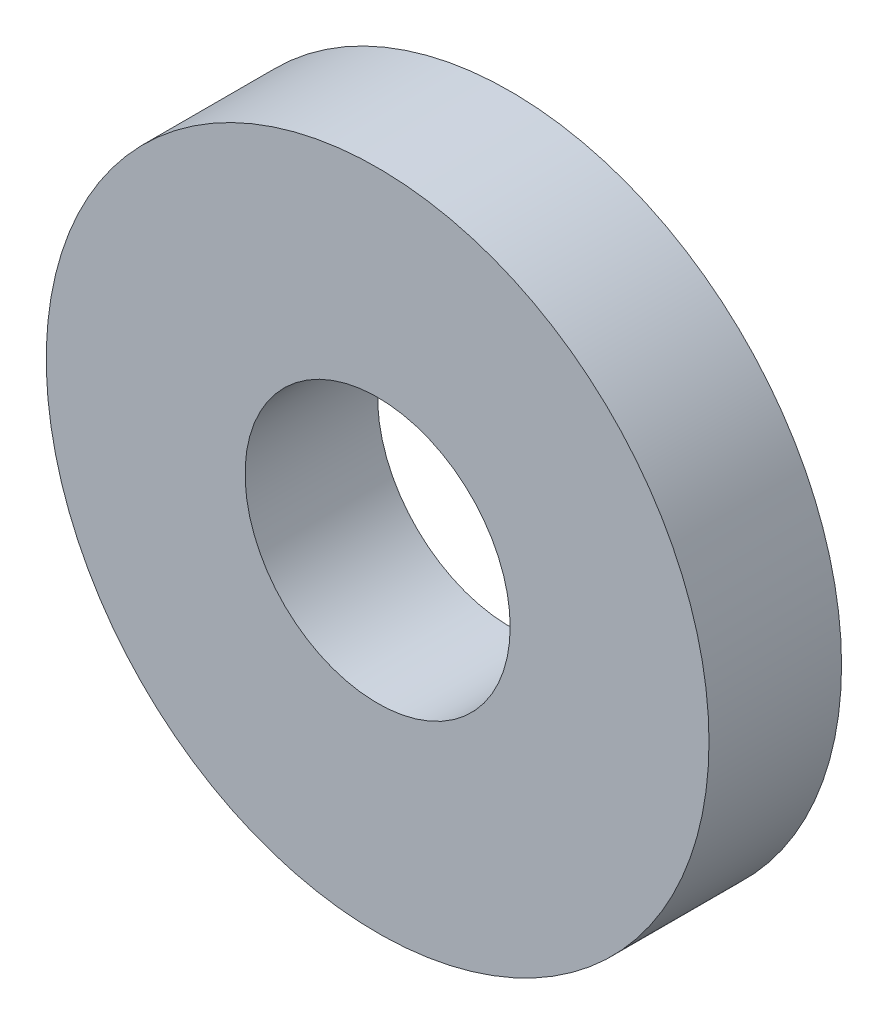
from build123d import *

# Parameters (mm, degrees)
SKETCH1_R           = 12.5
SKETCH1_R_2         = 5
BOSS_EXTRUDE1_DEPTH = 5


with BuildPart() as part:
    # Sketch1 → Boss-Extrude1 (new body)
    with BuildSketch(Plane.XY):
        Circle(SKETCH1_R)
        Circle(SKETCH1_R_2, mode=Mode.SUBTRACT)
    extrude(amount=BOSS_EXTRUDE1_DEPTH)


solid = part.part
